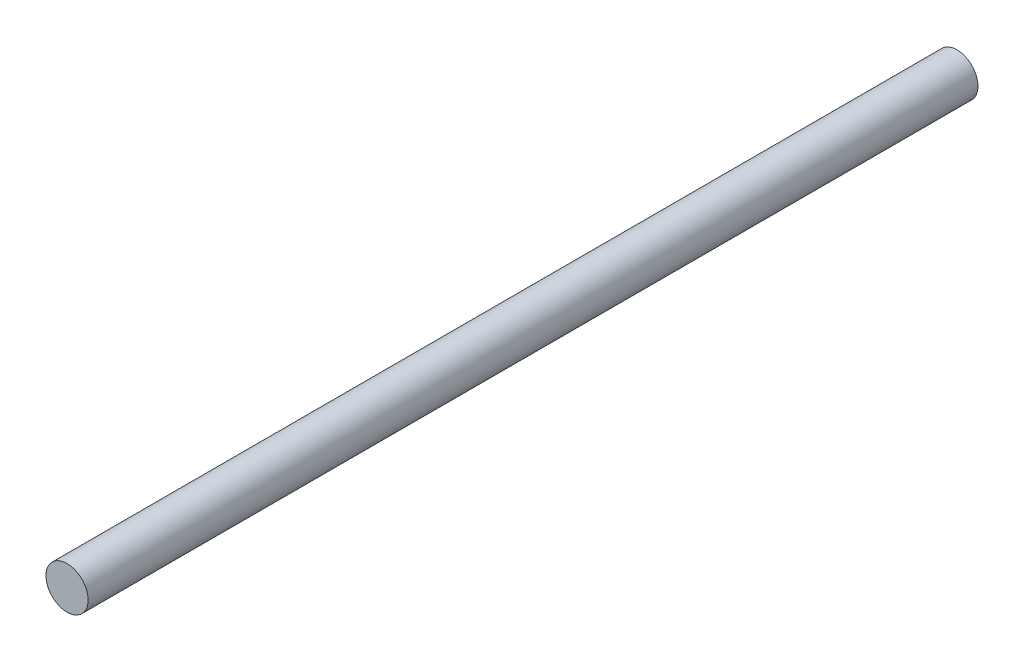
from build123d import *

# Parameters (mm, degrees)
SKETCH1_R           = 2.286
BOSS_EXTRUDE1_DEPTH = 96.52


with BuildPart() as part:
    # Sketch1 → Boss-Extrude1 (new body)
    with BuildSketch(Plane.XY):
        Circle(SKETCH1_R)
    extrude(amount=BOSS_EXTRUDE1_DEPTH)


solid = part.part
